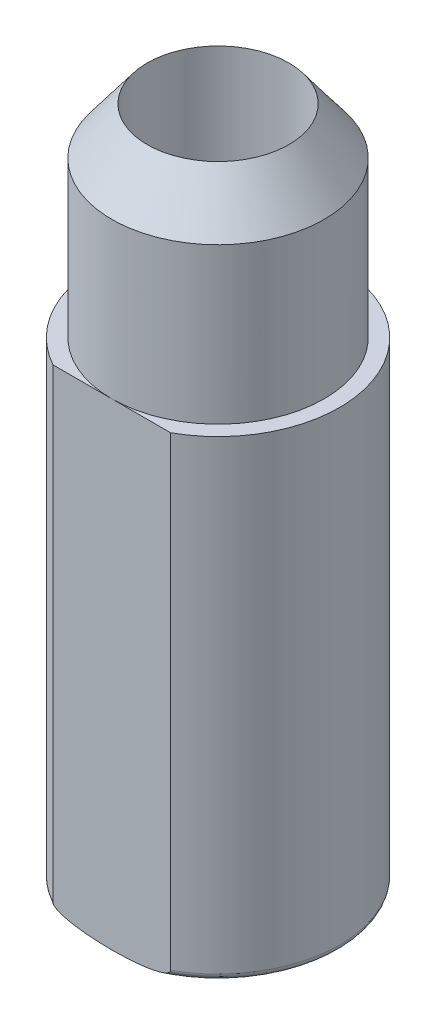
from build123d import *

# Parameters (mm, degrees)
SKETCH1_R           = 19.05
SKETCH1_R_2         = 11.1125
BOSS_EXTRUDE1_DEPTH = 76.2
SKETCH2_R           = 16.66875
SKETCH2_R_2         = 11.1125
BOSS_EXTRUDE2_DEPTH = 31.75
CUT_EXTRUDE1_DEPTH  = 81.82230509


with BuildPart() as part:
    # Sketch1 → Boss-Extrude1 (new body)
    with BuildSketch(Plane(origin=(0, 0, 0), x_dir=(1, 0, 0), z_dir=(0, 1, 0))):
        Circle(SKETCH1_R)
        Circle(SKETCH1_R_2, mode=Mode.SUBTRACT)
    extrude(amount=BOSS_EXTRUDE1_DEPTH)

    # Sketch2 → Boss-Extrude2 (add)
    with BuildSketch(Plane(origin=(0, 76.2, 0), x_dir=(1, 0, 0), z_dir=(0, 1, 0))):
        Circle(SKETCH2_R)
        Circle(SKETCH2_R_2, mode=Mode.SUBTRACT)
    extrude(amount=BOSS_EXTRUDE2_DEPTH)

    # Sketch3 → Cut-Revolve1 (revolve, cut)
    with BuildSketch(Plane(origin=(0, 0, 0), x_dir=(0, 0, -1), z_dir=(1, 0, 0))):
        Polygon((16.66875, 107.95), (16.66875, 100.57660721), (11.1125, 107.95), align=None)
    revolve(axis=Axis((0, 107.95, 0), (0, 1, 0)), mode=Mode.SUBTRACT)

    # Sketch4 → Cut-Extrude1 (cut, through all)
    with BuildSketch(Plane(origin=(0, 76.2, 0), x_dir=(1, 0, 0), z_dir=(0, 1, 0))):
        with BuildLine():
            Line((24.271104702, -16.66875), (-24.271104702, -16.66875))
            ThreePointArc((-24.271104702, -16.66875), (0, -29.443738723), (24.271104702, -16.66875))
        make_face()
    extrude(amount=-CUT_EXTRUDE1_DEPTH, mode=Mode.SUBTRACT)

    # Sketch8 → Cut-Revolve4 (revolve, cut)
    with BuildSketch(Plane.XY):
        with BuildLine():
            Line((0, 0), (-6.35, 0))
            add(Edge.make_bspline(
                [(-19.05, 3.175), (-19.05, 0), (-6.35, 0)],
                knots=[3.141592654, 3.141592654, 3.141592654, 4.71238898, 4.71238898, 4.71238898], degree=2, weights=[1, 0.707106781, 1]))
            Line((-19.05, 3.175), (-19.05, -4.469484217))
            Line((-19.05, -4.469484217), (0, -4.469484217))
            Line((0, -4.469484217), (0, 0))
        make_face()
    revolve(axis=Axis((0, 0, 0), (0, 1, 0)), mode=Mode.SUBTRACT)


solid = part.part
